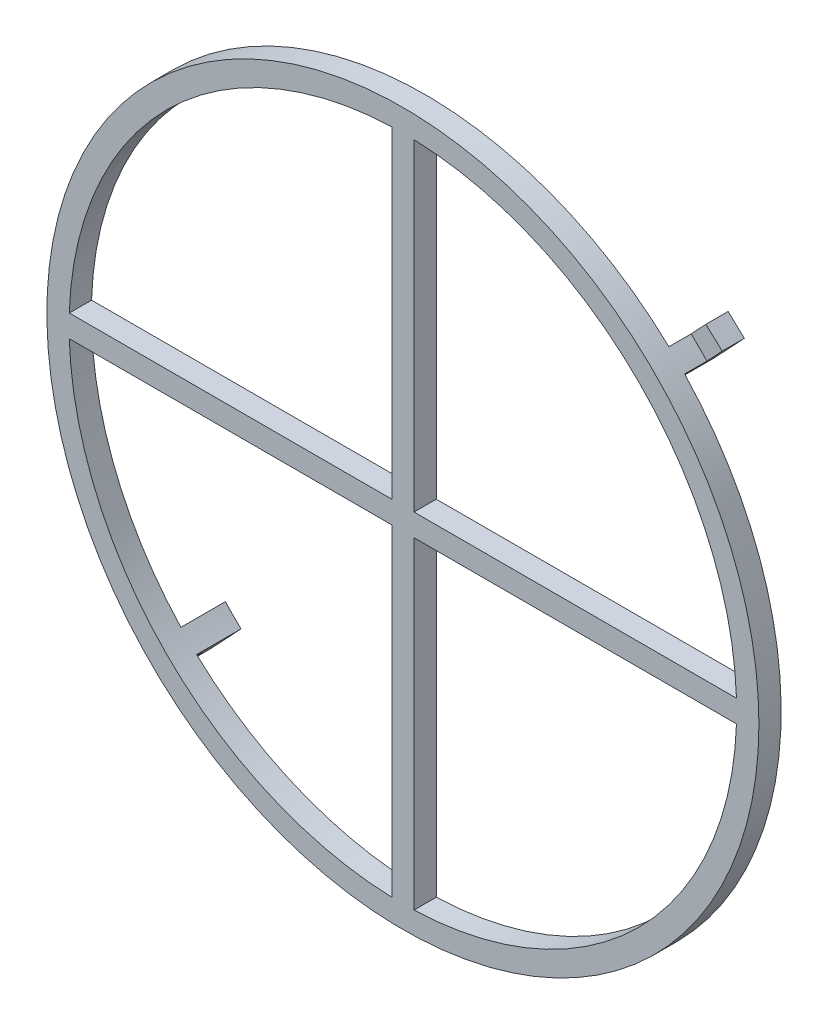
from build123d import *

# Parameters (mm, degrees)
SKETCH1_R           = 16
BOSS_EXTRUDE1_DEPTH = 1
BOSS_EXTRUDE2_DEPTH = 1
BOSS_EXTRUDE3_DEPTH = 1
CIRPATTERN1_COUNT   = 2


with BuildPart() as part:
    # Sketch1 → Boss-Extrude1 (new body)
    with BuildSketch(Plane.XY):
        Circle(SKETCH1_R)
        with BuildLine():
            Line((-0.5, 14.991664351), (-0.5, 0.5))
            Line((-0.5, 0.5), (-14.991664351, 0.5))
            ThreePointArc((-14.991664351, 0.5), (-10.606601718, 10.606601718), (-0.5, 14.991664351))
        make_face(mode=Mode.SUBTRACT)
        with BuildLine():
            Line((0.5, 14.991664351), (0.5, 0.5))
            Line((0.5, 0.5), (14.991664351, 0.5))
            ThreePointArc((14.991664351, 0.5), (10.606601718, 10.606601718), (0.5, 14.991664351))
        make_face(mode=Mode.SUBTRACT)
        with BuildLine():
            Line((-14.991664351, -0.5), (-0.5, -0.5))
            Line((-0.5, -0.5), (-0.5, -14.991664351))
            ThreePointArc((-0.5, -14.991664351), (-10.606601718, -10.606601718), (-14.991664351, -0.5))
        make_face(mode=Mode.SUBTRACT)
        with BuildLine():
            Line((0.5, -0.5), (14.991664351, -0.5))
            ThreePointArc((14.991664351, -0.5), (10.606601718, -10.606601718), (0.5, -14.991664351))
            Line((0.5, -14.991664351), (0.5, -0.5))
        make_face(mode=Mode.SUBTRACT)
    extrude(amount=BOSS_EXTRUDE1_DEPTH)

    # Sketch3 → Boss-Extrude2 (add)
    with BuildSketch(Plane(origin=(0, 0, 0), x_dir=(-1, 0, 0), z_dir=(0, 0, -1))):
        with BuildLine():
            Line((-11.661770518, 10.954593027), (-10.97567443, 10.224214923))
            ThreePointArc((-10.97567443, 10.224214923), (-10.628744174, 10.58441294), (-10.269999326, 10.932845642))
            Line((-10.269999326, 10.932845642), (-10.954665948, 11.661702018))
            ThreePointArc((-10.954665948, 11.661702018), (-11.313743872, 11.313673126), (-11.661770518, 10.954593027))
        make_face()
    boss_extrude2 = extrude(amount=BOSS_EXTRUDE2_DEPTH)

    # Sketch4 → Boss-Extrude3 (add)
    with BuildSketch(Plane(origin=(0, 0, -1), x_dir=(-1, 0, 0), z_dir=(0, 0, -1))):
        with BuildLine():
            Line((-11.661770518, 10.954593027), (-10.97567443, 10.224214923))
            ThreePointArc((-10.97567443, 10.224214923), (-10.628744174, 10.58441294), (-10.269999326, 10.932845642))
            Line((-10.269999326, 10.932845642), (-10.954665948, 11.661702018))
            Line((-10.954665948, 11.661702018), (-11.617936738, 12.367781633))
            Line((-11.617936738, 12.367781633), (-12.34643714, 11.683449403))
            Line((-12.34643714, 11.683449403), (-11.661770518, 10.954593027))
        make_face()
    boss_extrude3 = extrude(amount=BOSS_EXTRUDE3_DEPTH)

    # CirPattern1: Boss-Extrude2, Boss-Extrude3 ×2 about axis
    cirpattern1_axis = Axis((0, 0, 0), (0, 0, 1))
    for i in range(1, CIRPATTERN1_COUNT):
        add(boss_extrude2.rotate(cirpattern1_axis, i * 360 / CIRPATTERN1_COUNT))
        add(boss_extrude3.rotate(cirpattern1_axis, i * 360 / CIRPATTERN1_COUNT))


solid = part.part
